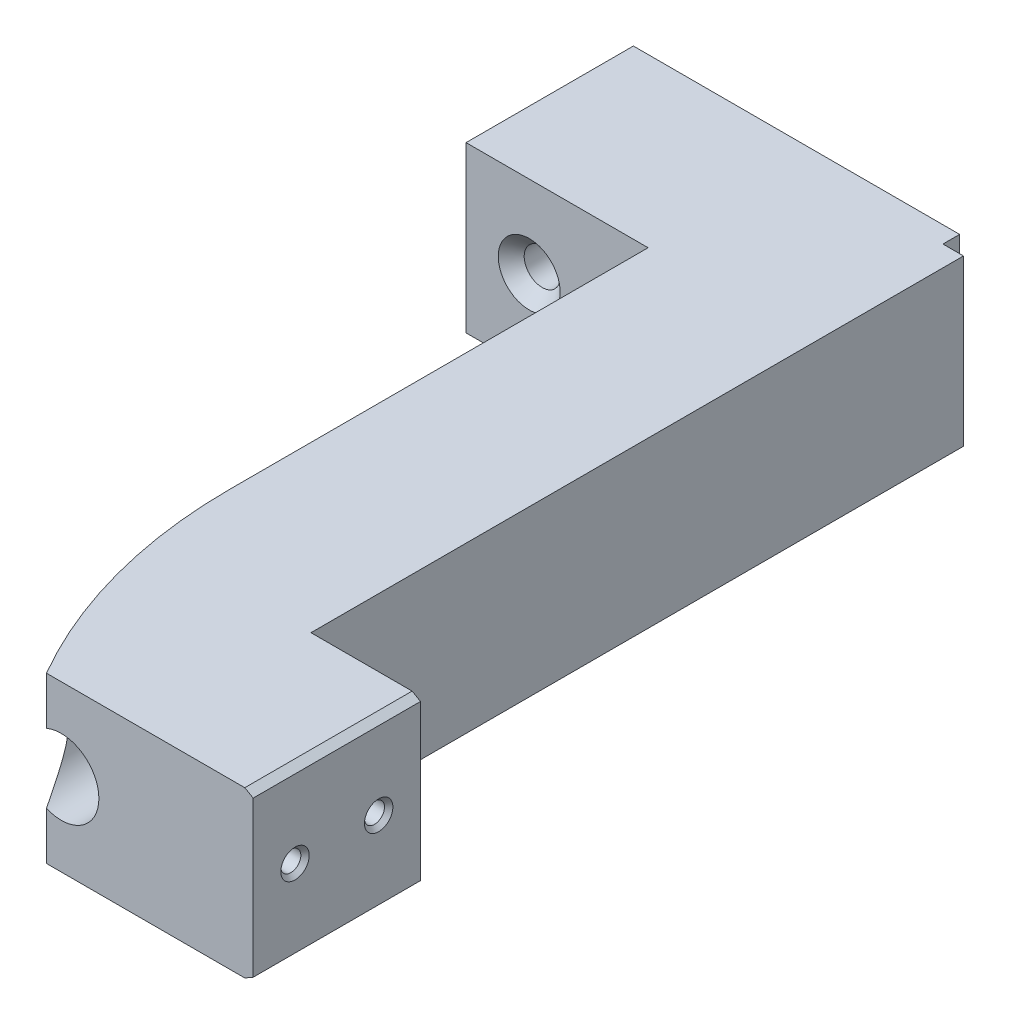
from build123d import *

# Parameters (mm, degrees)
SCHIZZO1_W                             = 39
SCHIZZO1_H                             = 19.7
ESTRUSIONE_ESTRUSIONE1_DEPTH           = 20
FORO_SVASATO_PER_VITE_M4_1_D           = 4.3
FORO_SVASATO_PER_VITE_M4_1_DEPTH       = 20
FORO_SVASATO_PER_VITE_M4_1_CSINK_D     = 7.4
FORO_SVASATO_PER_VITE_M4_1_CSINK_ANGLE = 90
ESTRUSIONE_ESTRUSIONE4_DEPTH           = 80
SCHIZZO7_W                             = 2.463088349
SCHIZZO7_H                             = 19.7
ESTRUSIONE_ESTRUSIONE5_DEPTH           = 18
TAGLIO_ESTRUSIONE2_DEPTH               = 20.7
SCHIZZO17_W                            = 20
SCHIZZO17_H                            = 19.7
ESTRUSIONE_ESTRUSIONE7_DEPTH           = 13.09
SMUSSO1_SIZE                           = 1
SMUSSO1_SIZE2                          = 0.577350269
SMUSSO1_PART_2_SIZE                    = 1
SMUSSO1_PART_2_SIZE2                   = 0.577350269
FORO_SVASATO_PER_VITE_M2_1_D           = 2.4
FORO_SVASATO_PER_VITE_M2_1_DEPTH       = 5
FORO_SVASATO_PER_VITE_M2_1_CSINK_D     = 3.4
FORO_SVASATO_PER_VITE_M2_1_CSINK_ANGLE = 90
FORO_SVASATO_PER_VITE_M2_1_TIP         = 0.721032743


with BuildPart() as part:
    # Schizzo1 → Estrusione-Estrusione1 (new body)
    with BuildSketch(Plane.XY):
        with Locations((19.5, 9.85)):
            Rectangle(SCHIZZO1_W, SCHIZZO1_H)
    extrude(amount=ESTRUSIONE_ESTRUSIONE1_DEPTH)

    # Foro svasato per Vite M4-1
    with Locations(Plane(origin=(7.55, 9.85, 20), x_dir=(1, 0, 0), z_dir=(0, 0, 1))):
        with Locations((0, 0), (24.063088349, 0)):
            CounterSinkHole(FORO_SVASATO_PER_VITE_M4_1_D / 2, FORO_SVASATO_PER_VITE_M4_1_CSINK_D / 2, depth=FORO_SVASATO_PER_VITE_M4_1_DEPTH, counter_sink_angle=FORO_SVASATO_PER_VITE_M4_1_CSINK_ANGLE)

    # Schizzo2 → Estrusione-Estrusione4 (add)
    with BuildSketch(Plane.XY.offset(20)):
        with BuildLine():
            Line((21.763088349, 19.7), (21.763088349, 9.85))
            Line((21.763088349, 9.85), (27.113088349, 9.85))
            ThreePointArc((27.113088349, 9.85), (31.613088349, 14.35), (36.113088349, 9.85))
            Line((36.113088349, 9.85), (39, 9.85))
            Line((39, 9.85), (39, 19.7))
            Line((39, 19.7), (21.763088349, 19.7))
        make_face()
        with BuildLine():
            Line((27.113088349, 9.85), (21.763088349, 9.85))
            Line((21.763088349, 9.85), (21.763088349, 0))
            Line((21.763088349, 0), (39, 0))
            Line((39, 0), (39, 9.85))
            Line((39, 9.85), (36.113088349, 9.85))
            ThreePointArc((36.113088349, 9.85), (31.613088349, 5.35), (27.113088349, 9.85))
        make_face()
        Polygon((39, 9.85), (39, 0), (41.463088349, 0), (41.463088349, 19.7), (39, 19.7), align=None)
    extrude(amount=ESTRUSIONE_ESTRUSIONE4_DEPTH)

    # Schizzo7 → Estrusione-Estrusione5 (add)
    with BuildSketch(Plane(origin=(0, 0, 20), x_dir=(-1, 0, 0), z_dir=(0, 0, -1))):
        with Locations((-40.231544175, 9.85)):
            Rectangle(SCHIZZO7_W, SCHIZZO7_H)
    extrude(amount=ESTRUSIONE_ESTRUSIONE5_DEPTH)

    # Schizzo9 → Taglio-Estrusione2 (cut, through all)
    with BuildSketch(Plane(origin=(0, 19.7, 0), x_dir=(1, 0, 0), z_dir=(0, 1, 0))):
        with BuildLine():
            Line((21.763088349, -70), (21.763088349, -100))
            Line((21.763088349, -100), (29.848264897, -100))
            ThreePointArc((29.848264897, -100), (23.81981051, -85.535202604), (21.763088349, -70))
        make_face()
    extrude(amount=-TAGLIO_ESTRUSIONE2_DEPTH, mode=Mode.SUBTRACT)

    # Schizzo17 → Estrusione-Estrusione7 (add)
    with BuildSketch(Plane(origin=(41.463088349, 0, 0), x_dir=(0, 0, -1), z_dir=(1, 0, 0))):
        with Locations((-90, 9.85)):
            Rectangle(SCHIZZO17_W, SCHIZZO17_H)
    extrude(amount=ESTRUSIONE_ESTRUSIONE7_DEPTH)

    # Smusso1
    smusso1_edges = [part.edges().sort_by_distance(p)[0] for p in [
        (54.553088349, 0, 90),
    ]]
    smusso1_side = [part.faces().sort_by_distance(p)[0] for p in [
        (29.991928904, 0, 46.112902696),
    ]]
    chamfer(smusso1_edges, length=SMUSSO1_SIZE, length2=SMUSSO1_SIZE2, reference=smusso1_side[0])

    # Smusso1 part 2
    smusso1_part_2_edges = [part.edges().sort_by_distance(p)[0] for p in [
        (54.553088349, 19.7, 90),
    ]]
    smusso1_part_2_side = [part.faces().sort_by_distance(p)[0] for p in [
        (29.991928904, 19.7, 46.112902696),
    ]]
    chamfer(smusso1_part_2_edges, length=SMUSSO1_PART_2_SIZE, length2=SMUSSO1_PART_2_SIZE2, reference=smusso1_part_2_side[0])

    # Foro svasato per Vite M2-1
    with Locations(Plane(origin=(54.553088349, 9.85, 95), x_dir=(0, 0, 1), z_dir=(1, 0, 0))):
        with Locations((0, 0), (-10, 0)):
            CounterSinkHole(FORO_SVASATO_PER_VITE_M2_1_D / 2, FORO_SVASATO_PER_VITE_M2_1_CSINK_D / 2, depth=FORO_SVASATO_PER_VITE_M2_1_DEPTH, counter_sink_angle=FORO_SVASATO_PER_VITE_M2_1_CSINK_ANGLE)
            with Locations((0, 0, -(FORO_SVASATO_PER_VITE_M2_1_DEPTH + FORO_SVASATO_PER_VITE_M2_1_TIP / 2))):  # 118° drill point
                Cone(0, FORO_SVASATO_PER_VITE_M2_1_D / 2, FORO_SVASATO_PER_VITE_M2_1_TIP, mode=Mode.SUBTRACT)


solid = part.part
